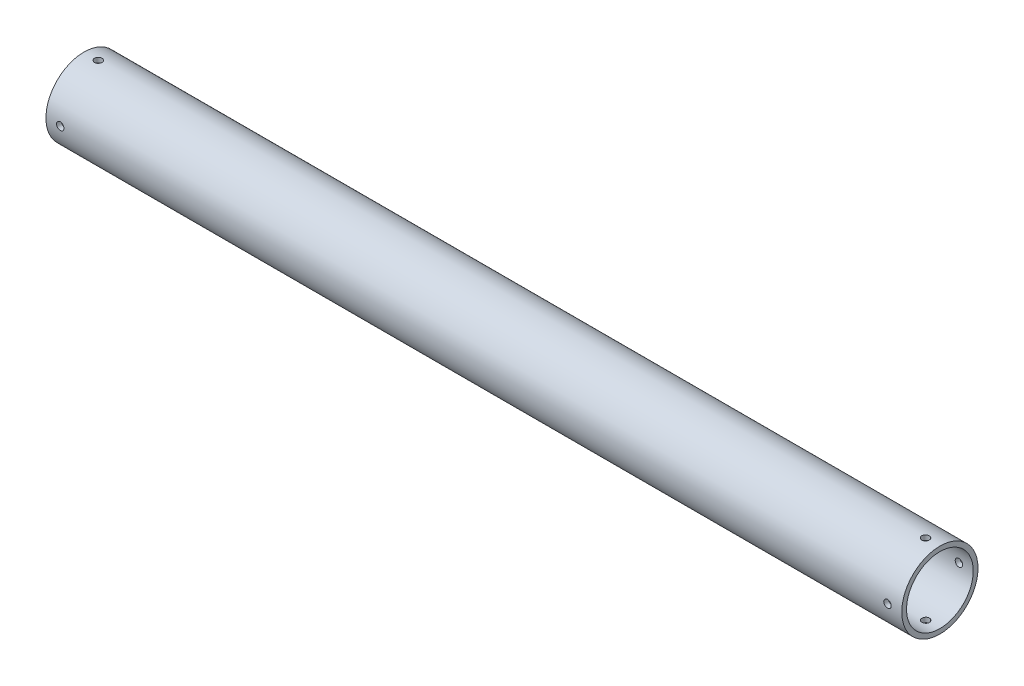
from build123d import *

# Parameters (mm, degrees)
SKETCH1_R               = 25.4
SKETCH1_R_2             = 22.225
BOSS_EXTRUDE1_DEPTH     = 285.115
SKETCH2_R               = 2.4892
CUT_EXTRUDE1_DEPTH      = 26.4
CUT_EXTRUDE1_DEPTH_BACK = 26.4
SKETCH3_R               = 2.4892
CUT_EXTRUDE2_DEPTH      = 26.4000001
CUT_EXTRUDE2_DEPTH_BACK = 26.4000001


with BuildPart() as part:
    # Sketch1 → Boss-Extrude1 (new body, symmetric)
    with BuildSketch(Plane(origin=(0, 0, 0), x_dir=(0, 0, -1), z_dir=(1, 0, 0))):
        Circle(SKETCH1_R)
        Circle(SKETCH1_R_2, mode=Mode.SUBTRACT)
    extrude(amount=BOSS_EXTRUDE1_DEPTH, both=True)

    # Sketch2 → Cut-Extrude1 (cut, two sides)
    with BuildSketch(Plane.XY) as cut_extrude1_sk:
        with Locations((-275.59, 0)):
            Circle(SKETCH2_R)
        with Locations((275.59, 0)):
            Circle(SKETCH2_R)
    extrude(amount=CUT_EXTRUDE1_DEPTH, mode=Mode.SUBTRACT)
    extrude(cut_extrude1_sk.sketch, amount=-CUT_EXTRUDE1_DEPTH_BACK, mode=Mode.SUBTRACT)

    # Sketch3 → Cut-Extrude2 (cut, two sides)
    with BuildSketch(Plane(origin=(0, 0, 0), x_dir=(1, 0, 0), z_dir=(0, 1, 0))) as cut_extrude2_sk:
        with Locations((-275.59, 0)):
            Circle(SKETCH3_R)
        with Locations((275.59, 0)):
            Circle(SKETCH3_R)
    extrude(amount=CUT_EXTRUDE2_DEPTH, mode=Mode.SUBTRACT)
    extrude(cut_extrude2_sk.sketch, amount=-CUT_EXTRUDE2_DEPTH_BACK, mode=Mode.SUBTRACT)


solid = part.part
